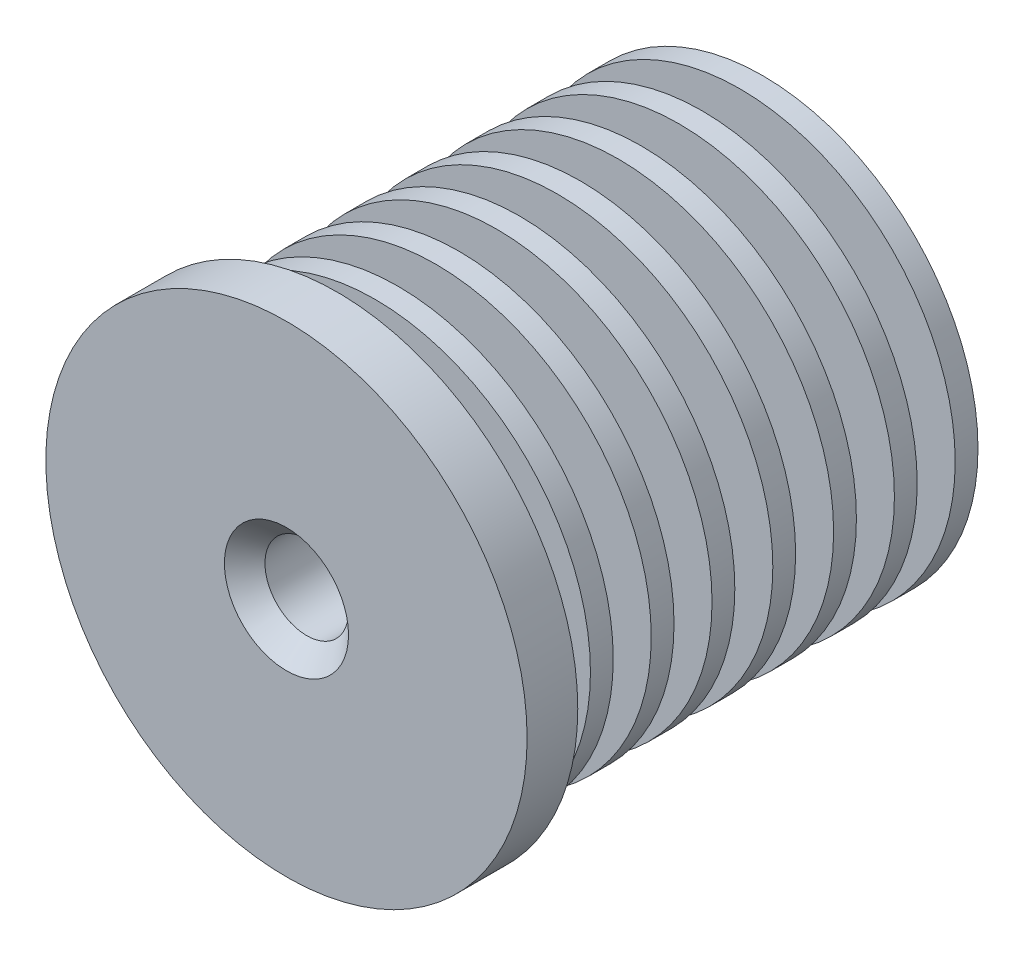
from build123d import *

# Parameters (mm, degrees)
CHAMFER1_SIZE = 0.8


with BuildPart() as part:
    # Sketch2 → Revolve1 (revolve)
    with BuildSketch(Plane(origin=(0, 0, 0), x_dir=(1, 0, 0), z_dir=(0, 1, 0))):
        Polygon((1.65, 18.8), (1.65, 0), (9.5, 0), (9.5, 2), (6, 2), (6, 3.5), (8.5, 3.5), (8.5, 4.4), (3.5, 4.4), (3.5, 5.9), (8.5, 5.9), (8.5, 6.8), (3.5, 6.8), (3.5, 8.3), (8.5, 8.3), (8.5, 9.2), (3.5, 9.2), (3.5, 10.7), (8.5, 10.7), (8.5, 11.6), (3.5, 11.6), (3.5, 13.1), (8.5, 13.1), (8.5, 14), (3.5, 14), (3.5, 15.5), (8.5, 15.5), (8.5, 16.4), (3.5, 16.4), (3.5, 17.9), (8.5, 17.9), (8.5, 18.8), align=None)
    revolve(axis=Axis((0, 0, 0), (0, 0, -1)))

    # Chamfer1
    chamfer1_edges = [part.edges().sort_by_distance(p)[0] for p in [
        (-1.65, 0, 0),
    ]]
    chamfer(chamfer1_edges, length=CHAMFER1_SIZE)


solid = part.part
